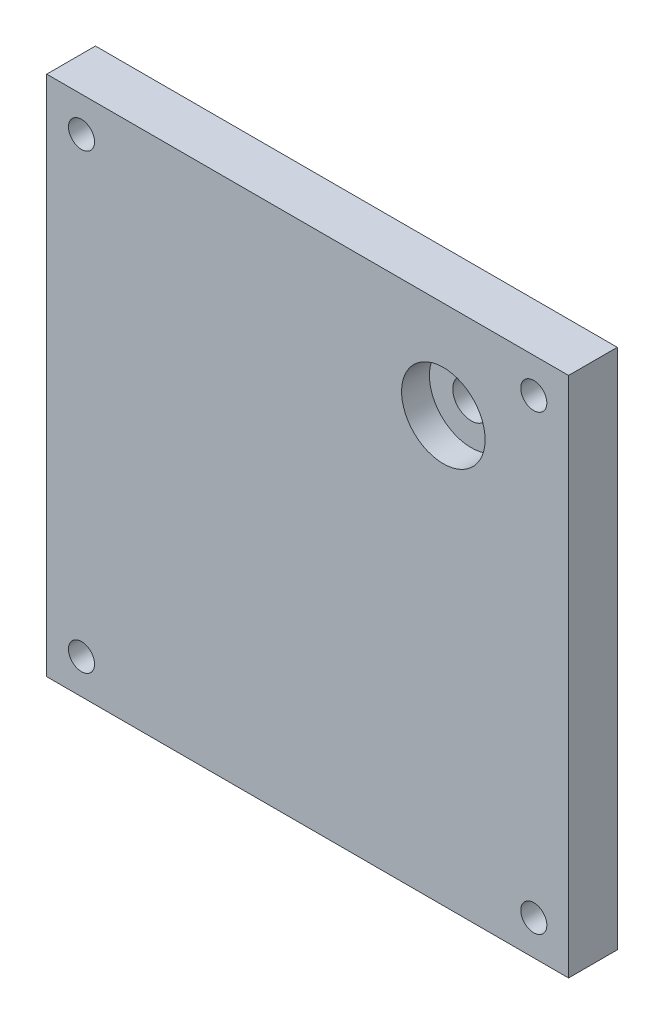
from build123d import *

# Parameters (mm, degrees)
SKETCH1_W           = 95.25
SKETCH1_H           = 95.25
BOSS_EXTRUDE1_DEPTH = 8.89
SKETCH2_OUTSIDE_W   = 124.25
SKETCH2_OUTSIDE_H   = 124.25
SKETCH2_OUTSIDE_W_2 = 95.25
SKETCH2_OUTSIDE_H_2 = 95.25
SKETCH2_OUTSIDE_R   = 2.38125
CUT_EXTRUDE2_DEPTH  = 9.89
SKETCH3_R           = 7.62
CUT_EXTRUDE3_DEPTH  = 5.08
SKETCH4_R           = 3.3655
CUT_EXTRUDE4_DEPTH  = 4.81


with BuildPart() as part:
    # Sketch1 → Boss-Extrude1 (new body)
    with BuildSketch(Plane.XY):
        Rectangle(SKETCH1_W, SKETCH1_H)
    extrude(amount=BOSS_EXTRUDE1_DEPTH)

    # Sketch2 outside → Cut-Extrude2 (cut, through all)
    with BuildSketch(Plane.XY.offset(8.89)):
        Rectangle(SKETCH2_OUTSIDE_W, SKETCH2_OUTSIDE_H)
        Rectangle(SKETCH2_OUTSIDE_W_2, SKETCH2_OUTSIDE_H_2, mode=Mode.SUBTRACT)
        with Locations((-41.275, 41.275)):
            Circle(SKETCH2_OUTSIDE_R)
        with Locations((41.275, 41.275)):
            Circle(SKETCH2_OUTSIDE_R)
        with Locations((41.275, -41.275)):
            Circle(SKETCH2_OUTSIDE_R)
        with Locations((-41.275, -41.275)):
            Circle(SKETCH2_OUTSIDE_R)
    extrude(amount=-CUT_EXTRUDE2_DEPTH, mode=Mode.SUBTRACT)

    # Sketch3 → Cut-Extrude3 (cut)
    with BuildSketch(Plane.XY.offset(8.89)):
        with Locations((24.765, 29.845)):
            Circle(SKETCH3_R)
    extrude(amount=-CUT_EXTRUDE3_DEPTH, mode=Mode.SUBTRACT)

    # Sketch4 → Cut-Extrude4 (cut, through all)
    with BuildSketch(Plane.XY.offset(3.81)):
        with Locations((24.765, 29.845)):
            Circle(SKETCH4_R)
    extrude(amount=-CUT_EXTRUDE4_DEPTH, mode=Mode.SUBTRACT)


solid = part.part
